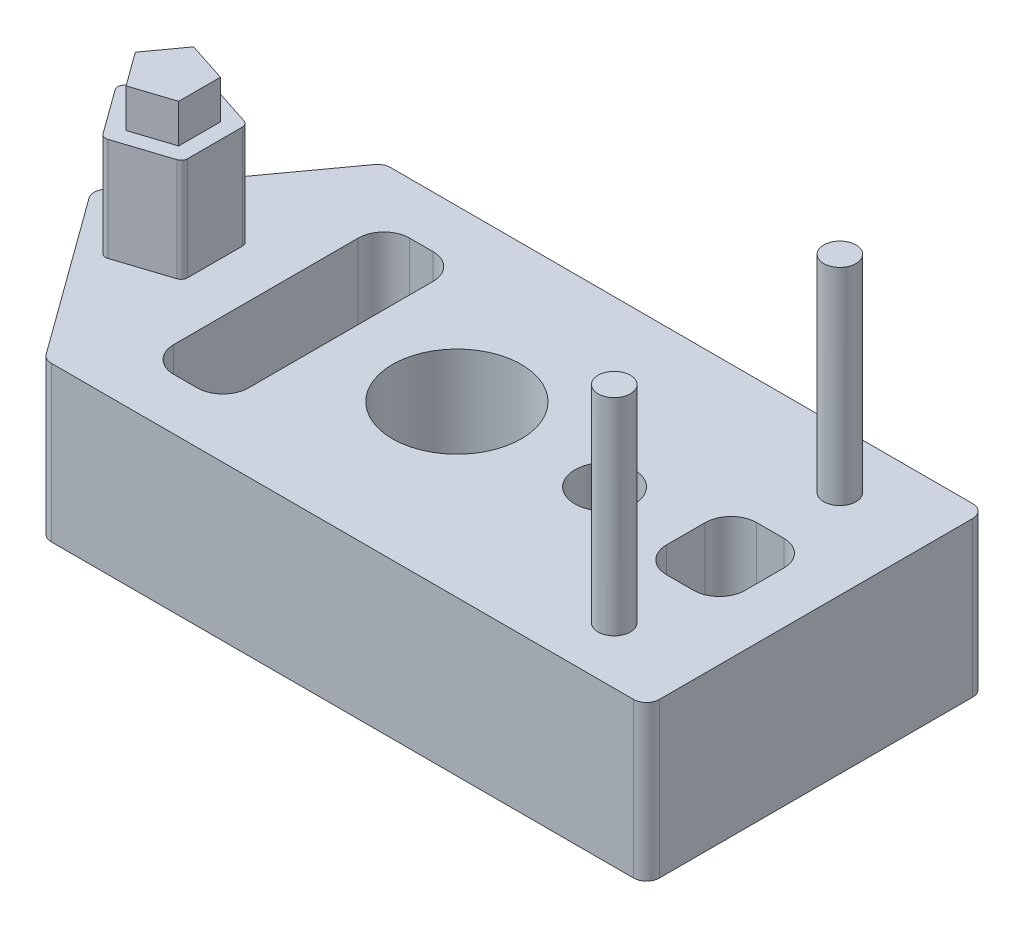
from build123d import *

# Parameters (mm, degrees)
BOSS_EXTRUDE2_DEPTH = 12
SKETCH3_R           = 5
SKETCH3_R_2         = 2.3
CUT_EXTRUDE1_DEPTH  = 13
SKETCH5_R           = 1.25
BOSS_EXTRUDE3_DEPTH = 16
BOSS_EXTRUDE4_DEPTH = 11
CUT_EXTRUDE2_DEPTH  = 3
FILLET1_R           = 0.5
FILLET2_R           = 1
SKETCH9_W           = 5.813805644
SKETCH9_H           = 18.3
SKETCH9_W_2         = 6.1
SKETCH9_H_2         = 7
CUT_EXTRUDE3_DEPTH  = 13
FILLET3_R           = 2


with BuildPart() as part:
    # Sketch1 → Boss-Extrude2 (new body)
    with BuildSketch(Plane(origin=(0, 0, 0), x_dir=(1, 0, 0), z_dir=(0, 1, 0))):
        Polygon((27.85, 13.15), (-18.275666287, 13.15), (-18.813805644, 13.15), (-28.367839887, 0), (-18.813805644, -13.15), (-18.275666287, -13.15), (27.85, -13.15), align=None)
    extrude(amount=-BOSS_EXTRUDE2_DEPTH)

    # Sketch3 → Cut-Extrude1 (cut, through all)
    with BuildSketch(Plane(origin=(0, 0, 0), x_dir=(1, 0, 0), z_dir=(0, 1, 0))):
        Circle(SKETCH3_R)
        with Locations((11.45, 0)):
            Circle(SKETCH3_R_2)
    extrude(amount=-CUT_EXTRUDE1_DEPTH, mode=Mode.SUBTRACT)

    # Sketch5 → Boss-Extrude3 (add)
    with BuildSketch(Plane(origin=(0, 0, 0), x_dir=(1, 0, 0), z_dir=(0, 1, 0))):
        with Locations((20.95, -8.75)):
            Circle(SKETCH5_R)
        with Locations((20.95, 8.75)):
            Circle(SKETCH5_R)
    extrude(amount=BOSS_EXTRUDE3_DEPTH)

    # Sketch6 → Boss-Extrude4 (add)
    with BuildSketch(Plane(origin=(0, 0, 0), x_dir=(1, 0, 0), z_dir=(0, 1, 0))):
        Polygon((-26.423567977, 0), (-23.496516994, -4.028740053), (-18.760449017, -2.489898285), (-18.760449017, 2.489898285), (-23.496516994, 4.028740053), align=None)
    extrude(amount=BOSS_EXTRUDE4_DEPTH)

    # Sketch7 → Cut-Extrude2 (cut)
    with BuildSketch(Plane(origin=(0, 11, 0), x_dir=(1, 0, 0), z_dir=(0, 1, 0))):
        Polygon((-26.423567977, 0), (-23.496516994, -4.028740053), (-18.760449017, -2.489898285), (-18.760449017, 2.489898285), (-23.496516994, 4.028740053), align=None)
        Polygon((-24.940286405, 0), (-23.038157781, -2.618055448), (-19.960449017, -1.618047251), (-19.960449017, 1.618047251), (-23.038157781, 2.618055448), align=None, mode=Mode.SUBTRACT)
    extrude(amount=-CUT_EXTRUDE2_DEPTH, mode=Mode.SUBTRACT)

    # Fillet1
    fillet1_edges = [part.edges().sort_by_distance(p)[0] for p in [
        (-23.496516994, 4, -4.028740053),
        (-18.760449017, 4, -2.489898285),
        (-18.760449017, 4, 2.489898285),
        (-23.496516994, 4, 4.028740053),
        (-26.423567977, 4, 0),
    ]]
    fillet(fillet1_edges, radius=FILLET1_R)

    # Fillet2
    fillet2_edges = [part.edges().sort_by_distance(p)[0] for p in [
        (-18.813805644, -6, -13.15),
        (27.85, -6, -13.15),
        (27.85, -6, 13.15),
        (-18.813805644, -6, 13.15),
        (-28.367839887, -6, 0),
    ]]
    fillet(fillet2_edges, radius=FILLET2_R)

    # Sketch9 → Cut-Extrude3 (cut, through all)
    with BuildSketch(Plane(origin=(0, 0, 0), x_dir=(1, 0, 0), z_dir=(0, 1, 0))):
        with Locations((-11.906902822, 0)):
            Rectangle(SKETCH9_W, SKETCH9_H)
        with Locations((20.8, 0)):
            Rectangle(SKETCH9_W_2, SKETCH9_H_2)
    extrude(amount=-CUT_EXTRUDE3_DEPTH, mode=Mode.SUBTRACT)

    # Fillet3
    fillet3_edges = [part.edges().sort_by_distance(p)[0] for p in [
        (-9, -6, -9.15),
        (-9, -6, 9.15),
        (-14.813805644, -6, 9.15),
        (-14.813805644, -6, -9.15),
        (17.75, -6, 3.5),
        (17.75, -6, -3.5),
        (23.85, -6, -3.5),
        (23.85, -6, 3.5),
    ]]
    fillet(fillet3_edges, radius=FILLET3_R)


solid = part.part
